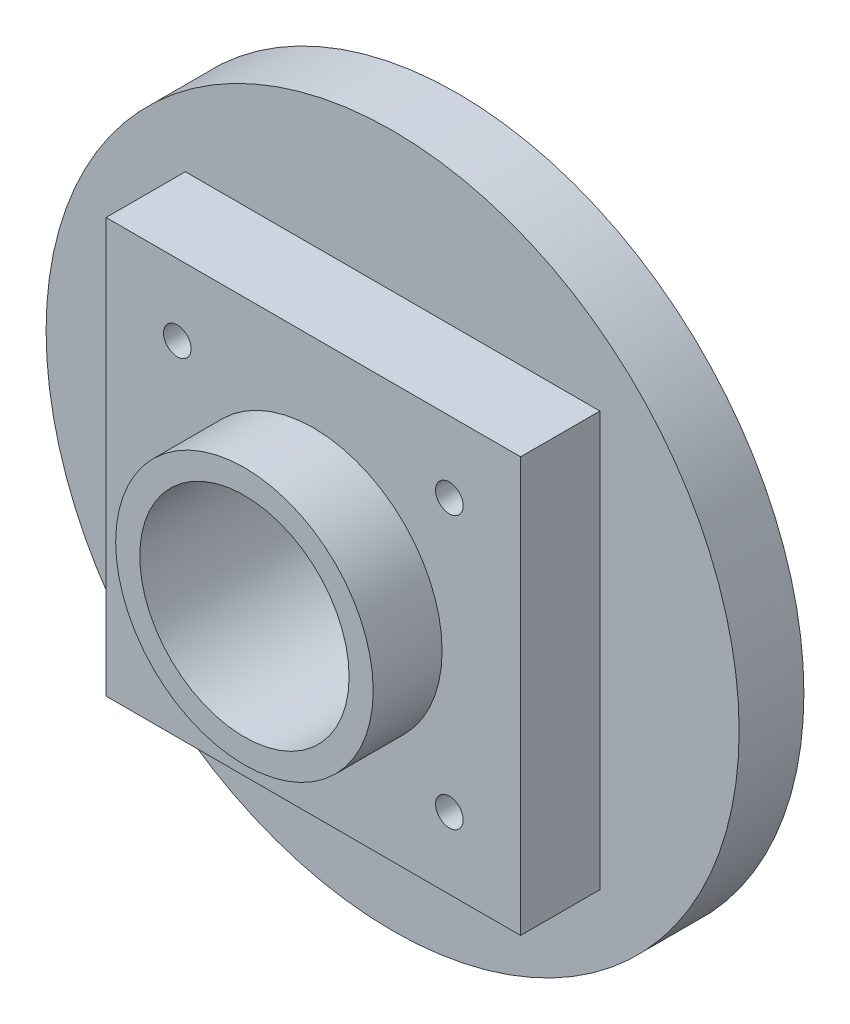
from build123d import *

# Parameters (mm, degrees)
SKETCH1_R                 = 33.9725
BOSS_EXTRUDE2_DEPTH       = 6.35
SKETCH2_R                 = 17.145
BOSS_EXTRUDE3_DEPTH       = 6.985
SKETCH3_W                 = 40.64
SKETCH3_H                 = 40.64
BOSS_EXTRUDE4_DEPTH       = 7.7724
SKETCH4_R                 = 10.2616
CUT_EXTRUDE1_DEPTH        = 22.1074
F_6_32_TAPPED_HOLE1_D     = 2.7051
F_6_32_TAPPED_HOLE1_DEPTH = 9.398
F_6_32_TAPPED_HOLE1_TIP   = 0.81269403
SKETCH8_R                 = 12.6238
SKETCH8_R_2               = 10.2616
BOSS_EXTRUDE5_DEPTH       = 6.7564


with BuildPart() as part:
    # Sketch1 → Boss-Extrude2 (new body)
    with BuildSketch(Plane.XY):
        Circle(SKETCH1_R)
    extrude(amount=BOSS_EXTRUDE2_DEPTH)

    # Sketch2 → Boss-Extrude3 (add)
    with BuildSketch(Plane(origin=(0, 0, 0), x_dir=(-1, 0, 0), z_dir=(0, 0, -1))):
        Circle(SKETCH2_R)
    extrude(amount=BOSS_EXTRUDE3_DEPTH)

    # Sketch3 → Boss-Extrude4 (add)
    with BuildSketch(Plane.XY.offset(6.35)):
        Rectangle(SKETCH3_W, SKETCH3_H)
    extrude(amount=BOSS_EXTRUDE4_DEPTH)

    # Sketch4 → Cut-Extrude1 (cut, through all)
    with BuildSketch(Plane.XY.offset(14.1224)):
        Circle(SKETCH4_R)
    extrude(amount=-CUT_EXTRUDE1_DEPTH, mode=Mode.SUBTRACT)

    # #6-32 Tapped Hole1
    with Locations(Plane.XY.offset(14.1224)):
        with Locations((-13.335, 13.335), (13.335, 13.335), (13.335, -13.335), (-13.335, -13.335)):
            Hole(F_6_32_TAPPED_HOLE1_D / 2, depth=F_6_32_TAPPED_HOLE1_DEPTH)
            with Locations((0, 0, -(F_6_32_TAPPED_HOLE1_DEPTH + F_6_32_TAPPED_HOLE1_TIP / 2))):  # 118° drill point
                Cone(0, F_6_32_TAPPED_HOLE1_D / 2, F_6_32_TAPPED_HOLE1_TIP, mode=Mode.SUBTRACT)

    # Sketch8 → Boss-Extrude5 (add)
    with BuildSketch(Plane.XY.offset(14.1224)):
        Circle(SKETCH8_R)
        Circle(SKETCH8_R_2, mode=Mode.SUBTRACT)
    extrude(amount=BOSS_EXTRUDE5_DEPTH)


solid = part.part
